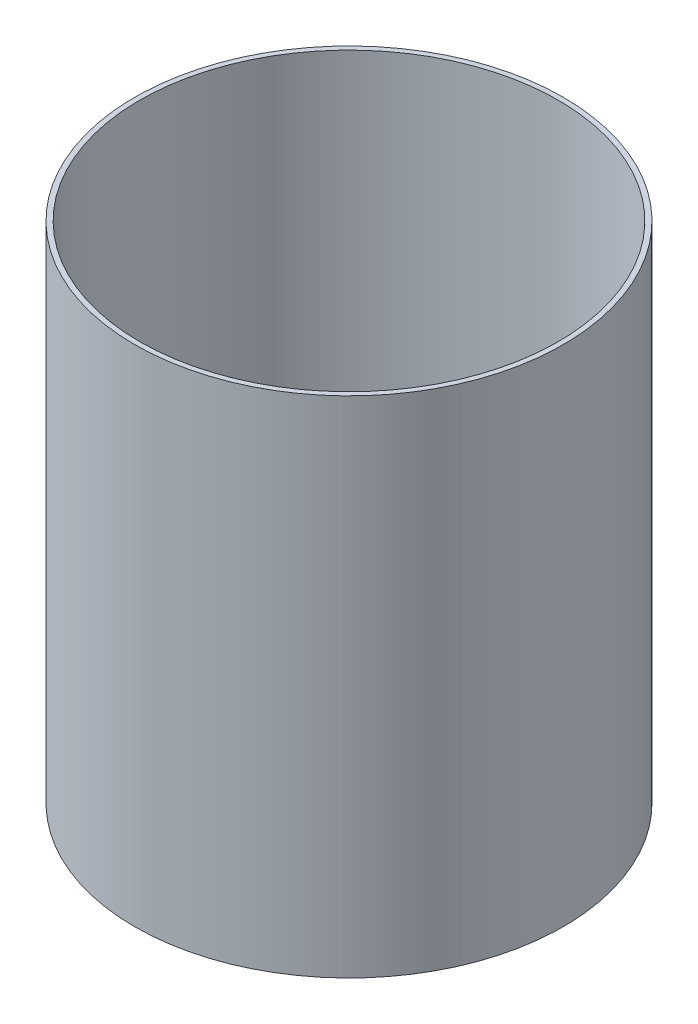
from build123d import *

# Parameters (mm, degrees)
SKETCH1_R           = 21.59
SKETCH1_R_2         = 21.082
BOSS_EXTRUDE1_DEPTH = 50.8


with BuildPart() as part:
    # Sketch1 → Boss-Extrude1 (new body)
    with BuildSketch(Plane(origin=(0, 0, 0), x_dir=(1, 0, 0), z_dir=(0, 1, 0))):
        Circle(SKETCH1_R)
        Circle(SKETCH1_R_2, mode=Mode.SUBTRACT)
    extrude(amount=BOSS_EXTRUDE1_DEPTH)


solid = part.part
